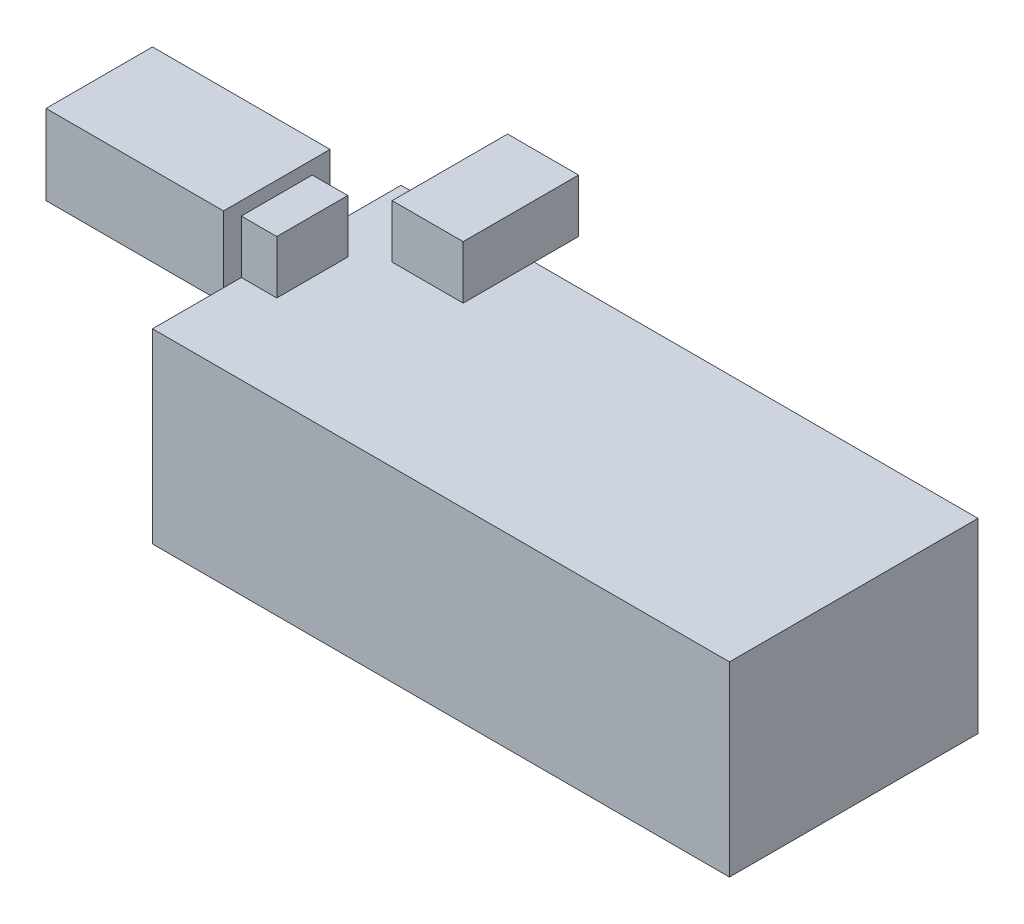
from build123d import *

# Parameters (mm, degrees)
SKETCH1_W           = 65
SKETCH1_H           = 28
BOSS_EXTRUDE1_DEPTH = 21
SKETCH3_W           = 4
SKETCH3_H           = 8
BOSS_EXTRUDE2_DEPTH = 6
SKETCH3_3_W         = 8
SKETCH3_3_H         = 8
BOSS_EXTRUDE3_DEPTH = 6
SKETCH4_W           = 12
SKETCH4_H           = 9
BOSS_EXTRUDE4_DEPTH = 20
SKETCH5_W           = 8
SKETCH5_H           = 6
BOSS_EXTRUDE5_DEPTH = 5


with BuildPart() as part:
    # Sketch1 → Boss-Extrude1 (new body)
    with BuildSketch(Plane(origin=(0, 0, 0), x_dir=(1, 0, 0), z_dir=(0, 1, 0))):
        Rectangle(SKETCH1_W, SKETCH1_H)
    extrude(amount=-BOSS_EXTRUDE1_DEPTH)

    # Sketch3 → Boss-Extrude2 (add)
    with BuildSketch(Plane(origin=(0, 0, 0), x_dir=(1, 0, 0), z_dir=(0, 1, 0))):
        with Locations((-30.5, 0)):
            Rectangle(SKETCH3_W, SKETCH3_H)
    extrude(amount=BOSS_EXTRUDE2_DEPTH)

    # Sketch3_3 → Boss-Extrude3 (add)
    with BuildSketch(Plane(origin=(0, 0, 0), x_dir=(1, 0, 0), z_dir=(0, 1, 0))):
        with Locations((-21.5, 10)):
            Rectangle(SKETCH3_3_W, SKETCH3_3_H)
    extrude(amount=BOSS_EXTRUDE3_DEPTH)

    # Sketch4 → Boss-Extrude4 (add)
    with BuildSketch(Plane.ZY.offset(32.5)):
        with Locations((0, 3)):
            Rectangle(SKETCH4_W, SKETCH4_H)
    extrude(amount=BOSS_EXTRUDE4_DEPTH)

    # Sketch5 → Boss-Extrude5 (add)
    with BuildSketch(Plane(origin=(0, 0, -14), x_dir=(-1, 0, 0), z_dir=(0, 0, -1))):
        with Locations((21.5, 3)):
            Rectangle(SKETCH5_W, SKETCH5_H)
    extrude(amount=BOSS_EXTRUDE5_DEPTH)


solid = part.part
